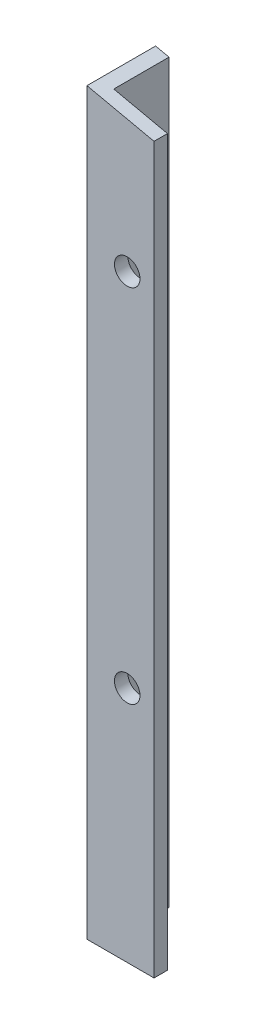
from build123d import *

# Parameters (mm, degrees)
BOSS_EXTRUDE1_DEPTH     = 140
CUT_EXTRUDE1_DEPTH      = 18.35
CUT_EXTRUDE1_DEPTH_BACK = 6.35
SKETCH3_R               = 2.415
CUT_EXTRUDE2_DEPTH      = 10
SKETCH4_R               = 2.415
CUT_EXTRUDE3_DEPTH      = 10
SKETCH5_R               = 2.415
CUT_EXTRUDE4_DEPTH      = 10
SKETCH6_R               = 2.415
CUT_EXTRUDE5_DEPTH      = 10


with BuildPart() as part:
    # Sketch1 → Boss-Extrude1 (new body)
    with BuildSketch(Plane(origin=(0, 0, 0), x_dir=(1, 0, 0), z_dir=(0, 1, 0))):
        Polygon((0, 0), (0, 12.99972), (2.54, 12.99972), (2.54, 2.54), (12.7, 2.54), (12.7, 0), align=None)
    extrude(amount=BOSS_EXTRUDE1_DEPTH)

    # Sketch2 → Cut-Extrude1 (cut, two sides)
    with BuildSketch(Plane(origin=(0, 0, -2.54), x_dir=(-1, 0, 0), z_dir=(0, 0, -1))) as cut_extrude1_sk:
        Polygon((-2.54, 139.443868054), (0, 140), (-11.159733345, 144.634657465), (-16.37733561, 136.414189162), (-12.7, 137.219340268), (-12.7, 140), (-2.54, 140), align=None)
        Polygon((-12.7, 137.219340268), (-2.54, 139.443868054), (-2.54, 140), (-12.7, 140), align=None)
    extrude(amount=CUT_EXTRUDE1_DEPTH, mode=Mode.SUBTRACT)
    extrude(cut_extrude1_sk.sketch, amount=-CUT_EXTRUDE1_DEPTH_BACK, mode=Mode.SUBTRACT)

    # Sketch3 → Cut-Extrude2 (cut)
    with BuildSketch(Plane(origin=(0, 0, -2.54), x_dir=(-1, 0, 0), z_dir=(0, 0, -1))):
        with Locations((-7.62, 113.331604161)):
            Circle(SKETCH3_R)
    extrude(amount=-CUT_EXTRUDE2_DEPTH, mode=Mode.SUBTRACT)

    # Sketch4 → Cut-Extrude3 (cut)
    with BuildSketch(Plane(origin=(2.54, 0, 0), x_dir=(0, 0, -1), z_dir=(1, 0, 0))):
        with Locations((7.76986, 94.443868054)):
            Circle(SKETCH4_R)
    extrude(amount=-CUT_EXTRUDE3_DEPTH, mode=Mode.SUBTRACT)

    # Sketch5 → Cut-Extrude4 (cut)
    with BuildSketch(Plane(origin=(2.54, 0, 0), x_dir=(0, 0, -1), z_dir=(1, 0, 0))):
        with Locations((7.76986, 60)):
            Circle(SKETCH5_R)
    extrude(amount=-CUT_EXTRUDE4_DEPTH, mode=Mode.SUBTRACT)

    # Sketch6 → Cut-Extrude5 (cut)
    with BuildSketch(Plane(origin=(0, 0, -2.54), x_dir=(-1, 0, 0), z_dir=(0, 0, -1))):
        with Locations((-7.62, 45)):
            Circle(SKETCH6_R)
    extrude(amount=-CUT_EXTRUDE5_DEPTH, mode=Mode.SUBTRACT)


solid = part.part
